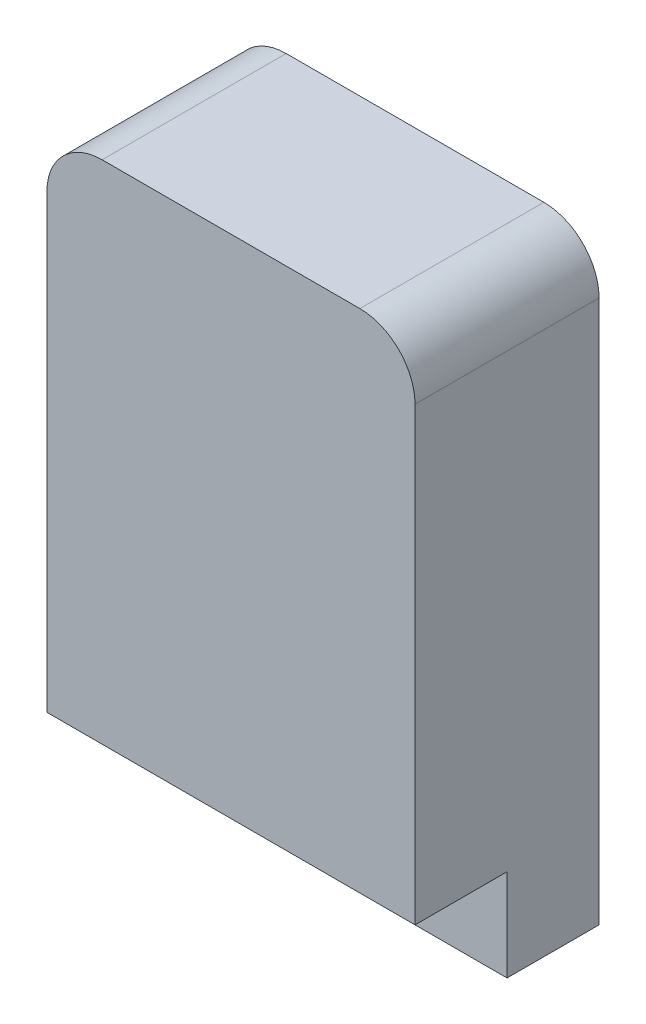
from build123d import *

# Parameters (mm, degrees)
SKETCH_1_R          = 7.5
EXTRUDE_1_DEPTH     = 10
SKETCH_1_3_W        = 20
SKETCH_1_3_H        = 5
EXTRUDE_2_DEPTH     = 5
SKETCH_1_4_R        = 7.5
CUT_EXTRUDE_1_DEPTH = 5


with BuildPart() as part:
    # Sketch 1 → Extrude 1 (new body)
    with BuildSketch(Plane.XY):
        with BuildLine():
            Line((-7, 10), (7, 10))
            ThreePointArc((7, 10), (9.121320344, 9.121320344), (10, 7))
            Line((10, 7), (10, -17.5))
            Line((10, -17.5), (-10, -17.5))
            Line((-10, -17.5), (-10, 7))
            ThreePointArc((-10, 7), (-9.121320344, 9.121320344), (-7, 10))
        make_face()
        Circle(SKETCH_1_R, mode=Mode.SUBTRACT)
        Circle(SKETCH_1_R)
    extrude(amount=EXTRUDE_1_DEPTH)

    # Sketch 1_3 → Extrude 2 (add)
    with BuildSketch(Plane.XY):
        with Locations((0, -20)):
            Rectangle(SKETCH_1_3_W, SKETCH_1_3_H)
    extrude(amount=EXTRUDE_2_DEPTH)

    # Sketch 1_4 → Cut-Extrude 1 (cut)
    with BuildSketch(Plane.XY):
        Circle(SKETCH_1_4_R)
    extrude(amount=CUT_EXTRUDE_1_DEPTH, mode=Mode.SUBTRACT)


solid = part.part
